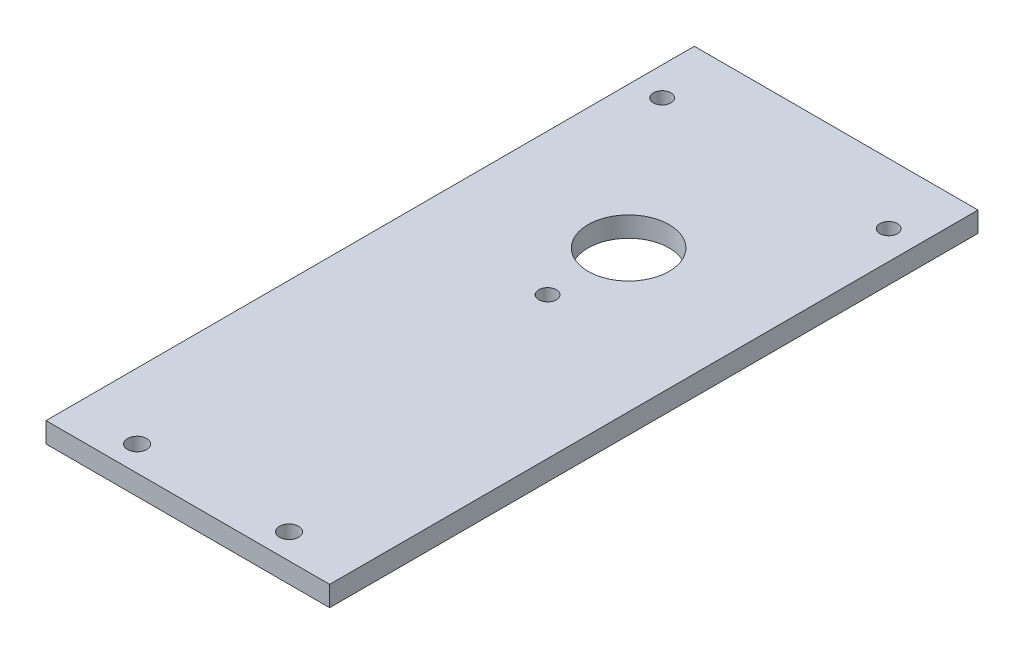
from build123d import *

# Parameters (mm, degrees)
SKETCH1_W           = 88.9
SKETCH1_H           = 203.2
BOSS_EXTRUDE1_DEPTH = 6.35
SKETCH2_R           = 3
SKETCH2_R_2         = 2.75
SKETCH2_R_3         = 12.7
CUT_EXTRUDE1_DEPTH  = 7.35


with BuildPart() as part:
    # Sketch1 → Boss-Extrude1 (new body)
    with BuildSketch(Plane(origin=(0, 0, 0), x_dir=(1, 0, 0), z_dir=(0, 1, 0))):
        with Locations((44.45, 101.6)):
            Rectangle(SKETCH1_W, SKETCH1_H)
    extrude(amount=BOSS_EXTRUDE1_DEPTH)

    # Sketch2 → Cut-Extrude1 (cut, through all)
    with BuildSketch(Plane.XZ):
        with Locations((20.6375, -7.913544442)):
            Circle(SKETCH2_R)
        with Locations((68.2625, -7.913544442)):
            Circle(SKETCH2_R)
        with Locations((44.45, -112.75)):
            Circle(SKETCH2_R_2)
        with Locations((8.95, -184.15)):
            Circle(SKETCH2_R_2)
        with Locations((79.95, -184.15)):
            Circle(SKETCH2_R_2)
        with Locations((44.45, -138.15)):
            Circle(SKETCH2_R_3)
    extrude(amount=-CUT_EXTRUDE1_DEPTH, mode=Mode.SUBTRACT)


solid = part.part
